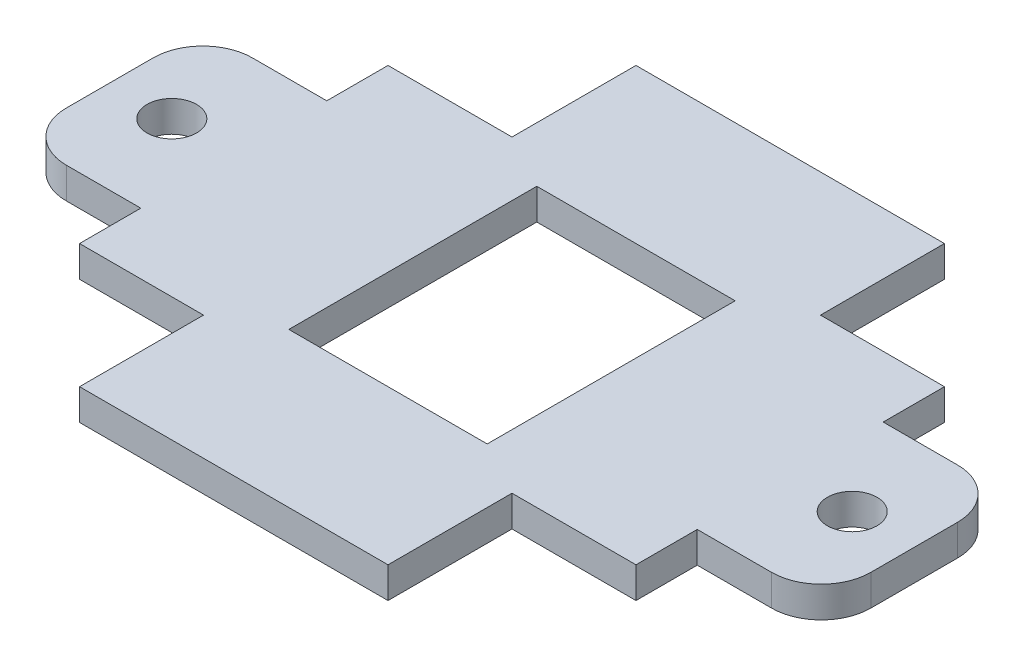
from build123d import *

# Parameters (mm, degrees)
SKETCH1_R           = 2.54
SKETCH1_W           = 20.32
SKETCH1_H           = 25.4
BOSS_EXTRUDE1_DEPTH = 3.175


with BuildPart() as part:
    # Sketch1 → Boss-Extrude1 (new body)
    with BuildSketch(Plane(origin=(0, 0, 0), x_dir=(1, 0, 0), z_dir=(0, 1, 0))):
        with BuildLine():
            Line((-28.4999938, 15.7999938), (-28.4999938, 9.525))
            Line((-28.4999938, 9.525), (-36.1199938, 9.525))
            ThreePointArc((-36.1199938, 9.525), (-39.712096248, 8.037102448), (-41.1999938, 4.445))
            Line((-41.1999938, 4.445), (-41.1999938, -4.445))
            ThreePointArc((-41.1999938, -4.445), (-39.712096248, -8.037102448), (-36.1199938, -9.525))
            Line((-36.1199938, -9.525), (-28.4999938, -9.525))
            Line((-28.4999938, -9.525), (-28.4999938, -15.7999938))
            Line((-28.4999938, -15.7999938), (-15.7999938, -15.7999938))
            Line((-15.7999938, -15.7999938), (-15.7999938, -28.4999938))
            Line((-15.7999938, -28.4999938), (15.7999938, -28.4999938))
            Line((15.7999938, -28.4999938), (15.7999938, -15.7999938))
            Line((15.7999938, -15.7999938), (28.4999938, -15.7999938))
            Line((28.4999938, -15.7999938), (28.4999938, -9.525))
            Line((28.4999938, -9.525), (36.1199938, -9.525))
            ThreePointArc((36.1199938, -9.525), (39.712096248, -8.037102448), (41.1999938, -4.445))
            Line((41.1999938, -4.445), (41.1999938, 4.445))
            ThreePointArc((41.1999938, 4.445), (39.712096248, 8.037102448), (36.1199938, 9.525))
            Line((36.1199938, 9.525), (28.4999938, 9.525))
            Line((28.4999938, 9.525), (28.4999938, 15.7999938))
            Line((28.4999938, 15.7999938), (15.7999938, 15.7999938))
            Line((15.7999938, 15.7999938), (15.7999938, 28.4999938))
            Line((15.7999938, 28.4999938), (-15.7999938, 28.4999938))
            Line((-15.7999938, 28.4999938), (-15.7999938, 15.7999938))
            Line((-15.7999938, 15.7999938), (-28.4999938, 15.7999938))
        make_face()
        with Locations((-34.8499938, 0)):
            Circle(SKETCH1_R, mode=Mode.SUBTRACT)
        with Locations((34.8499938, 0)):
            Circle(SKETCH1_R, mode=Mode.SUBTRACT)
        Rectangle(SKETCH1_W, SKETCH1_H, mode=Mode.SUBTRACT)
    extrude(amount=BOSS_EXTRUDE1_DEPTH)


solid = part.part
